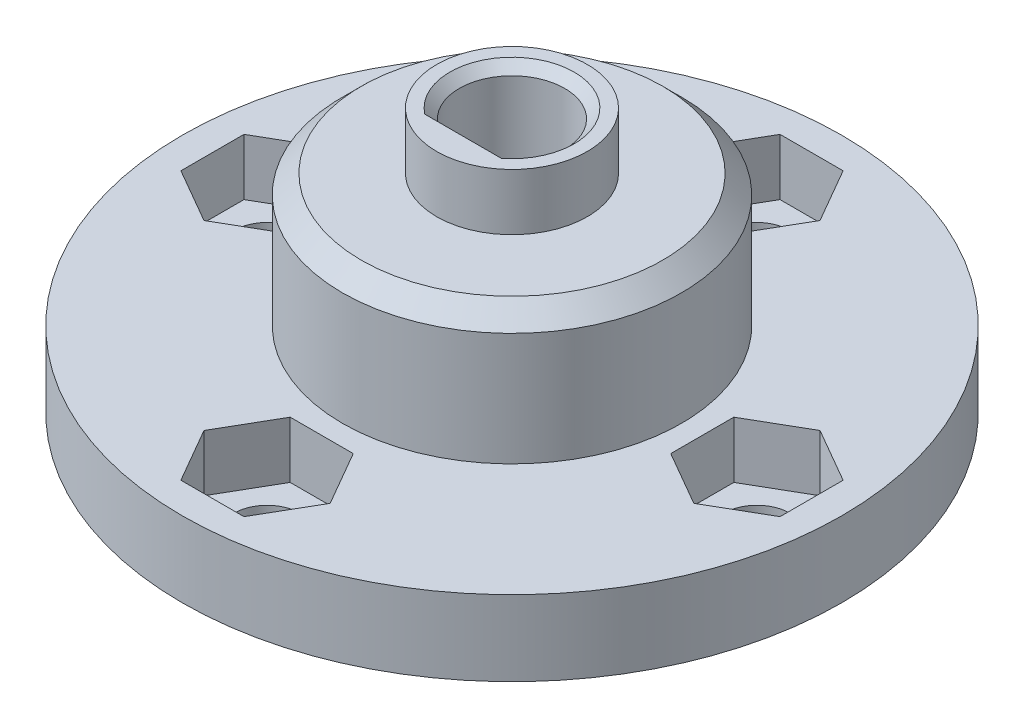
from build123d import *

# Parameters (mm, degrees)
SKETCH_1_R          = 17.5
SKETCH_1_R_2        = 1.75
EXTRUDE_1_DEPTH     = 4
CUT_EXTRUDE_1_DEPTH = 3
SKETCH_3_R          = 9
EXTRUDE_2_DEPTH     = 7
CUT_EXTRUDE_2_DEPTH = 2
SKETCH_6_R          = 4
EXTRUDE_3_DEPTH     = 3
CHAMFER_1_SIZE      = 1
CHAMFER_2_SIZE      = 0.5


with BuildPart() as part:
    # Эскиз1 → Бобышка-Вытянуть1 (new body)
    with BuildSketch(Plane(origin=(0, 0, 0), x_dir=(1, 0, 0), z_dir=(0, 1, 0))):
        Circle(SKETCH_1_R)
        with Locations((13, 0)):
            Circle(SKETCH_1_R_2, mode=Mode.SUBTRACT)
        with Locations((0, -13)):
            Circle(SKETCH_1_R_2, mode=Mode.SUBTRACT)
        with Locations((-13, 0)):
            Circle(SKETCH_1_R_2, mode=Mode.SUBTRACT)
        with Locations((0, 13)):
            Circle(SKETCH_1_R_2, mode=Mode.SUBTRACT)
    extrude(amount=EXTRUDE_1_DEPTH)

    # Эскиз2 → Вырез-Вытянуть1 (cut)
    with BuildSketch(Plane(origin=(0, 4, 0), x_dir=(1, 0, 0), z_dir=(0, 1, 0))):
        Polygon((3.348631561, 13), (1.674315781, 15.9), (-1.674315781, 15.9), (-3.348631561, 13), (-1.674315781, 10.1), (1.674315781, 10.1), align=None)
        Polygon((-13, -3.348631561), (-10.1, -1.674315781), (-10.1, 1.674315781), (-13, 3.348631561), (-15.9, 1.674315781), (-15.9, -1.674315781), align=None)
        Polygon((15.9, -1.674315781), (13, -3.348631561), (10.1, -1.674315781), (10.1, 1.674315781), (13, 3.348631561), (15.9, 1.674315781), align=None)
        Polygon((1.674315781, -10.1), (3.348631561, -13), (1.674315781, -15.9), (-1.674315781, -15.9), (-3.348631561, -13), (-1.674315781, -10.1), align=None)
    extrude(amount=-CUT_EXTRUDE_1_DEPTH, mode=Mode.SUBTRACT)

    # Эскиз3 → Бобышка-Вытянуть2 (add)
    with BuildSketch(Plane(origin=(0, 4, 0), x_dir=(1, 0, 0), z_dir=(0, 1, 0))):
        Circle(SKETCH_3_R)
        with BuildLine():
            Line((-1.852025918, -2.1), (1.852025918, -2.1))
            ThreePointArc((1.852025918, -2.1), (0, 2.8), (-1.852025918, -2.1))
        make_face(mode=Mode.SUBTRACT)
    extrude(amount=EXTRUDE_2_DEPTH)

    # Эскиз4 → Вырез-Вытянуть2 (cut)
    with BuildSketch(Plane(origin=(0, 4, 0), x_dir=(1, 0, 0), z_dir=(0, 1, 0))):
        with BuildLine():
            Line((-1.852025918, -2.1), (1.852025918, -2.1))
            ThreePointArc((1.852025918, -2.1), (0, 2.8), (-1.852025918, -2.1))
        make_face()
    extrude(amount=-CUT_EXTRUDE_2_DEPTH, mode=Mode.SUBTRACT)

    # Эскиз6 → Бобышка-Вытянуть3 (add)
    with BuildSketch(Plane(origin=(0, 11, 0), x_dir=(1, 0, 0), z_dir=(0, 1, 0))):
        Circle(SKETCH_6_R)
        with BuildLine():
            Line((-1.852025918, -2.1), (1.852025918, -2.1))
            ThreePointArc((1.852025918, -2.1), (0, 2.8), (-1.852025918, -2.1))
        make_face(mode=Mode.SUBTRACT)
    extrude(amount=EXTRUDE_3_DEPTH)

    # Фаска1
    chamfer_1_edges = [part.edges().sort_by_distance(p)[0] for p in [
        (-9, 11, 0),
    ]]
    chamfer(chamfer_1_edges, length=CHAMFER_1_SIZE)

    # Фаска2
    chamfer_2_edges = [part.edges().sort_by_distance(p)[0] for p in [
        (0, 14, -2.8),
        (0, 14, 2.1),
    ]]
    chamfer(chamfer_2_edges, length=CHAMFER_2_SIZE)


solid = part.part
